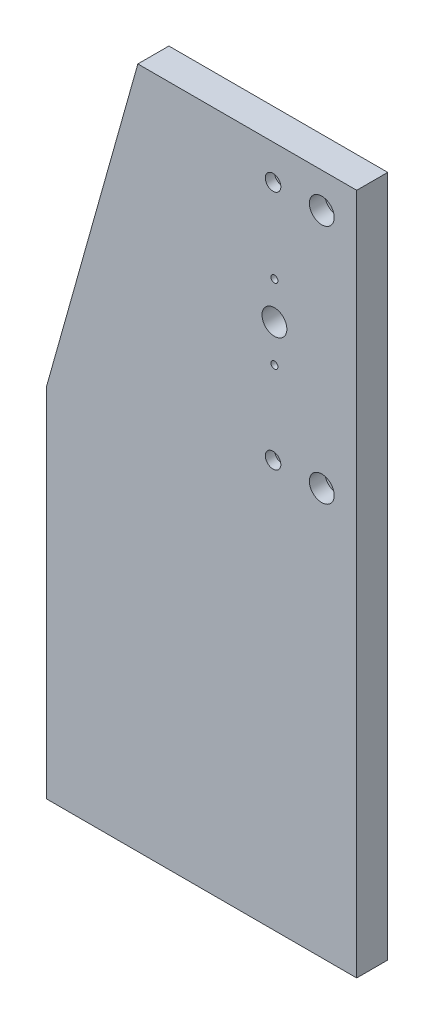
from build123d import *

# Parameters (mm, degrees)
SKETCH1_R          = 8
SKETCH1_R_2        = 5
SKETCH1_R_3        = 2.25
SKETCH1_R_4        = 3
EXTRUDE1_DEPTH     = 20
SKETCH3_R          = 8
CUT_EXTRUDE2_DEPTH = 10
SKETCH4_R          = 3.25
CUT_EXTRUDE3_DEPTH = 60
SKETCH5_R          = 5
CUT_EXTRUDE4_DEPTH = 6


with BuildPart() as part:
    # Sketch1 → Extrude1 (new body)
    with BuildSketch(Plane.XY):
        Polygon((-20, 229.5), (38.999908, 439.49994136), (180, 439.50001453), (180, 30), (180, 0), (-20, 0), (-20, 30), align=None)
        with Locations((126.999908, 339.49994136)):
            Circle(SKETCH1_R, mode=Mode.SUBTRACT)
        with Locations((157.49992067, 416.99997068)):
            Circle(SKETCH1_R_2, mode=Mode.SUBTRACT)
        with Locations((126.999908, 363.49994136)):
            Circle(SKETCH1_R_3, mode=Mode.SUBTRACT)
        with Locations((126.999908, 315.49994136)):
            Circle(SKETCH1_R_3, mode=Mode.SUBTRACT)
        with Locations((157.49992067, 261.99991204)):
            Circle(SKETCH1_R_2, mode=Mode.SUBTRACT)
        with Locations((126.12492067, 261.99991204)):
            Circle(SKETCH1_R_4, mode=Mode.SUBTRACT)
        with Locations((126.12492067, 416.99997068)):
            Circle(SKETCH1_R_4, mode=Mode.SUBTRACT)
    extrude(amount=EXTRUDE1_DEPTH)

    # Sketch3 → Cut-Extrude2 (cut)
    with BuildSketch(Plane.XY.offset(20)):
        with Locations((157.49992067, 416.99997068)):
            Circle(SKETCH3_R)
        with Locations((157.49992067, 261.99991204)):
            Circle(SKETCH3_R)
    extrude(amount=-CUT_EXTRUDE2_DEPTH, mode=Mode.SUBTRACT)

    # Sketch4 → Cut-Extrude3 (cut)
    with BuildSketch(Plane.XZ):
        with Locations((20, 10)):
            Circle(SKETCH4_R)
        with Locations((40, 10)):
            Circle(SKETCH4_R)
        with Locations((60, 10)):
            Circle(SKETCH4_R)
        with Locations((80, 10)):
            Circle(SKETCH4_R)
        with Locations((100, 10)):
            Circle(SKETCH4_R)
        with Locations((120, 10)):
            Circle(SKETCH4_R)
        with Locations((140, 10)):
            Circle(SKETCH4_R)
        with Locations((160, 10)):
            Circle(SKETCH4_R)
        with Locations((0, 10)):
            Circle(SKETCH4_R)
    extrude(amount=-CUT_EXTRUDE3_DEPTH, mode=Mode.SUBTRACT)

    # Sketch5 → Cut-Extrude4 (cut)
    with BuildSketch(Plane.XY.offset(20)):
        with Locations((126.12492067, 416.99997068)):
            Circle(SKETCH5_R)
        with Locations((126.12492067, 261.99991204)):
            Circle(SKETCH5_R)
    extrude(amount=-CUT_EXTRUDE4_DEPTH, mode=Mode.SUBTRACT)


solid = part.part
